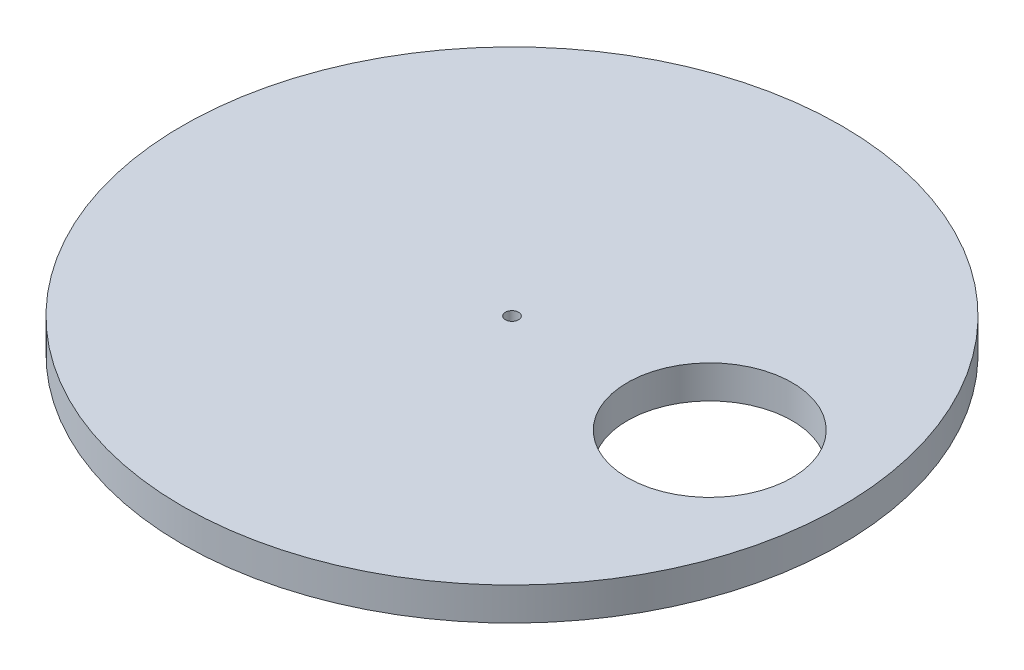
from build123d import *

# Parameters (mm, degrees)
CROQUIS1_R              = 100
CROQUIS1_R_2            = 25
CROQUIS1_R_3            = 2
SALIENTE_EXTRUIR1_DEPTH = 10


with BuildPart() as part:
    # Croquis1 → Saliente-Extruir1 (new body)
    with BuildSketch(Plane(origin=(0, 0, 0), x_dir=(1, 0, 0), z_dir=(0, 1, 0))):
        Circle(CROQUIS1_R)
        with Locations((60, 0)):
            Circle(CROQUIS1_R_2, mode=Mode.SUBTRACT)
        Circle(CROQUIS1_R_3, mode=Mode.SUBTRACT)
    extrude(amount=SALIENTE_EXTRUIR1_DEPTH)


solid = part.part
